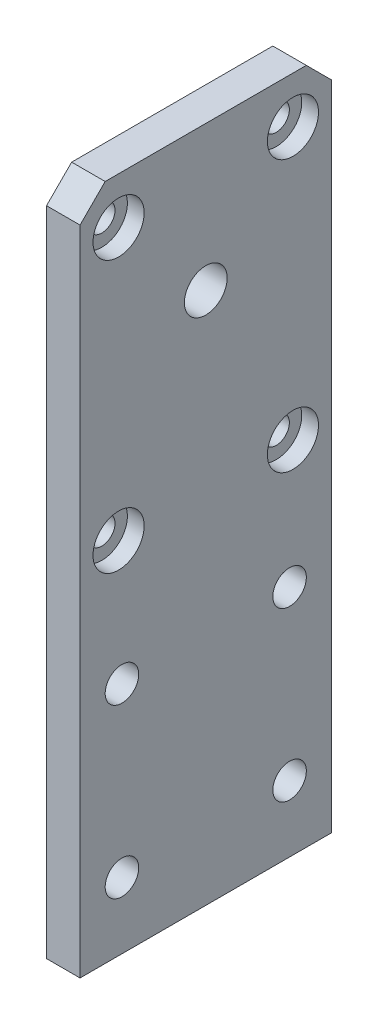
from build123d import *

# Parameters (mm, degrees)
CROQUIS1_W              = 30
CROQUIS1_H              = 80.8
SALIENTE_EXTRUIR1_DEPTH = 4
CROQUIS3_R              = 2
CORTAR_EXTRUIR2_DEPTH   = 5
CROQUIS8_R              = 2.55
CORTAR_EXTRUIR3_DEPTH   = 5
CROQUIS10_R             = 3.05
CORTAR_EXTRUIR4_DEPTH   = 2
CROQUIS11_R             = 1.575
CORTAR_EXTRUIR5_DEPTH   = 3
CHAFL_N1_SIZE           = 3


with BuildPart() as part:
    # Croquis1 → Saliente-Extruir1 (new body)
    with BuildSketch(Plane(origin=(0, 0, 0), x_dir=(0, 0, -1), z_dir=(1, 0, 0))):
        Rectangle(CROQUIS1_W, CROQUIS1_H)
    extrude(amount=SALIENTE_EXTRUIR1_DEPTH)

    # Croquis3 → Cortar-Extruir2 (cut, through all)
    with BuildSketch(Plane(origin=(4, 0, 0), x_dir=(0, 0, -1), z_dir=(1, 0, 0))):
        with Locations((-10, -12.5)):
            Circle(CROQUIS3_R)
        with Locations((10, -12.5)):
            Circle(CROQUIS3_R)
        with Locations((-10, -32.5)):
            Circle(CROQUIS3_R)
        with Locations((10, -32.5)):
            Circle(CROQUIS3_R)
    extrude(amount=-CORTAR_EXTRUIR2_DEPTH, mode=Mode.SUBTRACT)

    # Croquis8 → Cortar-Extruir3 (cut, through all)
    with BuildSketch(Plane.ZY):
        with Locations((0, 23.15)):
            Circle(CROQUIS8_R)
    extrude(amount=-CORTAR_EXTRUIR3_DEPTH, mode=Mode.SUBTRACT)

    # Croquis10 → Cortar-Extruir4 (cut)
    with BuildSketch(Plane.ZY.offset(-4)):
        with Locations((-10.4, 34.85)):
            Circle(CROQUIS10_R)
        with Locations((10.4, 34.85)):
            Circle(CROQUIS10_R)
        with Locations((10.4, 2.5)):
            Circle(CROQUIS10_R)
        with Locations((-10.4, 2.5)):
            Circle(CROQUIS10_R)
    extrude(amount=CORTAR_EXTRUIR4_DEPTH, mode=Mode.SUBTRACT)

    # Croquis11 → Cortar-Extruir5 (cut, through all)
    with BuildSketch(Plane(origin=(2, 0, 0), x_dir=(0, 0, -1), z_dir=(1, 0, 0))):
        with Locations((-10.4, 34.85)):
            Circle(CROQUIS11_R)
        with Locations((10.4, 34.85)):
            Circle(CROQUIS11_R)
        with Locations((10.4, 2.5)):
            Circle(CROQUIS11_R)
        with Locations((-10.4, 2.5)):
            Circle(CROQUIS11_R)
    extrude(amount=-CORTAR_EXTRUIR5_DEPTH, mode=Mode.SUBTRACT)

    # Chaflán1
    chafl_n1_edges = [part.edges().sort_by_distance(p)[0] for p in [
        (2, 40.4, 15),
        (2, 40.4, -15),
    ]]
    chamfer(chafl_n1_edges, length=CHAFL_N1_SIZE)


solid = part.part
